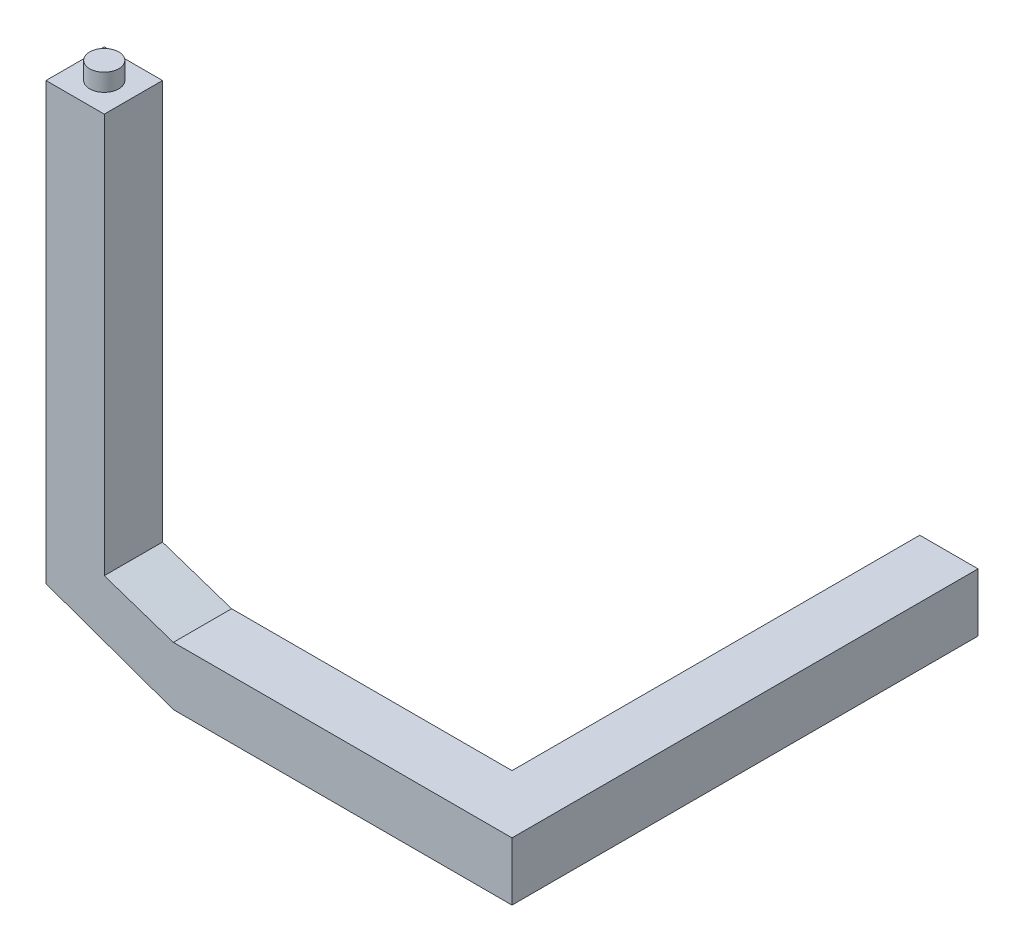
from build123d import *

# Parameters (mm, degrees)
SKETCH1_W           = 100
SKETCH1_H           = 100
BOSS_EXTRUDE1_DEPTH = 800
SKETCH2_W           = 100
SKETCH2_H           = 100
BOSS_EXTRUDE2_DEPTH = 700
BOSS_EXTRUDE3_DEPTH = 100
SKETCH5_R           = 25
BOSS_EXTRUDE4_DEPTH = 25
CUT_EXTRUDE2_DEPTH  = 801
BOSS_EXTRUDE5_DEPTH = 100
CUT_EXTRUDE3_DEPTH  = 801
SKETCH10_R          = 25
BOSS_EXTRUDE6_DEPTH = 30


with BuildPart() as part:
    # Sketch1 → Boss-Extrude1 (new body)
    with BuildSketch(Plane.XY):
        with Locations((50, 50)):
            Rectangle(SKETCH1_W, SKETCH1_H)
    extrude(amount=BOSS_EXTRUDE1_DEPTH)

    # Sketch2 → Boss-Extrude2 (add)
    with BuildSketch(Plane(origin=(0, 0, 0), x_dir=(0, 0, -1), z_dir=(1, 0, 0))):
        with Locations((-750, 50)):
            Rectangle(SKETCH2_W, SKETCH2_H)
    extrude(amount=-BOSS_EXTRUDE2_DEPTH)

    # Sketch4 → Boss-Extrude3 (add)
    with BuildSketch(Plane.XY.offset(800)):
        Polygon((-493.990986432, 0), (-600, -41.564522078), (-600, -730.356100977), (-700, -730.356100977), (-700, 0), align=None)
    extrude(amount=-BOSS_EXTRUDE3_DEPTH)

    # Sketch5 → Boss-Extrude4 (add)
    with BuildSketch(Plane(origin=(0, -730.356100977, 0), x_dir=(-1, 0, 0), z_dir=(0, -1, 0))):
        with Locations((650, -750)):
            Circle(SKETCH5_R)
    extrude(amount=BOSS_EXTRUDE4_DEPTH)

    # Sketch6 → Cut-Extrude2 (cut, through all)
    with BuildSketch(Plane.XY.offset(800)):
        Polygon((-700, 0), (-700, 77.872935738), (-481.374152596, 0), align=None)
    extrude(amount=-CUT_EXTRUDE2_DEPTH, mode=Mode.SUBTRACT)

    # Sketch8 → Boss-Extrude5 (add)
    with BuildSketch(Plane.XY.offset(800)):
        Polygon((-700, 100), (-600, 100), (-481.374152596, 100), (-600, 139.764231535), (-600, 826.035666916), (-700, 826.035666916), align=None)
    extrude(amount=-BOSS_EXTRUDE5_DEPTH)

    # Sketch9 → Cut-Extrude3 (cut, through all)
    with BuildSketch(Plane.XY.offset(800)):
        Polygon((-740.353325761, 0), (-493.364641431, 0), (-493.364641431, -882.481689371), (-837.990616097, -863.88243179), align=None)
    extrude(amount=-CUT_EXTRUDE3_DEPTH, mode=Mode.SUBTRACT)

    # Sketch10 → Boss-Extrude6 (add)
    with BuildSketch(Plane(origin=(0, 826.035666916, 0), x_dir=(1, 0, 0), z_dir=(0, 1, 0))):
        with Locations((-650, -750)):
            Circle(SKETCH10_R)
    extrude(amount=BOSS_EXTRUDE6_DEPTH)


solid = part.part
